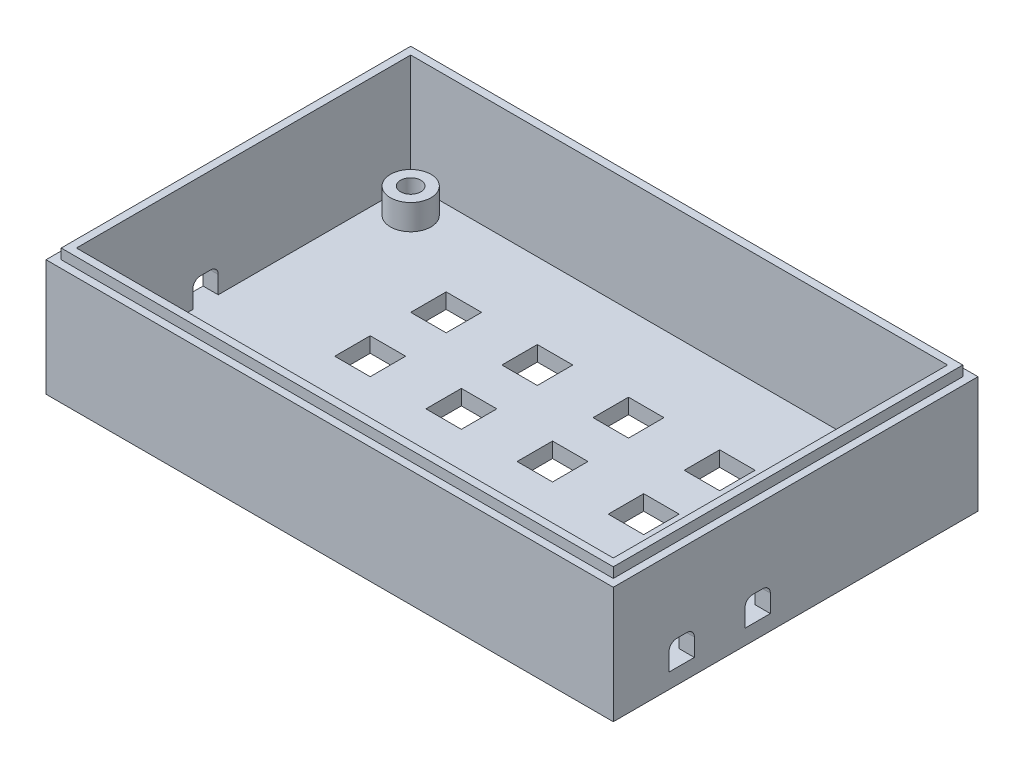
from build123d import *

# Parameters (mm, degrees)
SKETCH1_W                = 106
SKETCH1_H                = 66
SKETCH1_R                = 2
BOSS_EXTRUDE1_DEPTH      = 3
SKETCH2_W                = 112
SKETCH2_H                = 72
SKETCH2_W_2              = 106
SKETCH2_H_2              = 66
BOSS_EXTRUDE2_DEPTH      = 20
BOSS_EXTRUDE2_DEPTH_BACK = 3
SKETCH4_W                = 109
SKETCH4_H                = 69
SKETCH4_W_2              = 106
SKETCH4_H_2              = 66
BOSS_EXTRUDE3_DEPTH      = 2
CUT_EXTRUDE1_DEPTH       = 4
SKETCH6_R                = 4
SKETCH6_R_2              = 2
BOSS_EXTRUDE4_DEPTH      = 5
SKETCH7_W                = 7
SKETCH7_H                = 7
CUT_EXTRUDE2_DEPTH       = 4


with BuildPart() as part:
    # Sketch1 → Boss-Extrude1 (new body)
    with BuildSketch(Plane(origin=(0, 0, 0), x_dir=(1, 0, 0), z_dir=(0, 1, 0))):
        Rectangle(SKETCH1_W, SKETCH1_H)
        with Locations((-47.6, 27.6)):
            Circle(SKETCH1_R, mode=Mode.SUBTRACT)
        with Locations((47.6, 27.6)):
            Circle(SKETCH1_R, mode=Mode.SUBTRACT)
        with Locations((47.6, -27.6)):
            Circle(SKETCH1_R, mode=Mode.SUBTRACT)
        with Locations((-47.6, -27.6)):
            Circle(SKETCH1_R, mode=Mode.SUBTRACT)
    extrude(amount=BOSS_EXTRUDE1_DEPTH)

    # Sketch2 → Boss-Extrude2 (add, two sides)
    with BuildSketch(Plane(origin=(0, 3, 0), x_dir=(1, 0, 0), z_dir=(0, 1, 0))) as boss_extrude2_sk:
        Rectangle(SKETCH2_W, SKETCH2_H)
        Rectangle(SKETCH2_W_2, SKETCH2_H_2, mode=Mode.SUBTRACT)
    extrude(amount=BOSS_EXTRUDE2_DEPTH)
    extrude(boss_extrude2_sk.sketch, amount=-BOSS_EXTRUDE2_DEPTH_BACK)

    # Sketch4 → Boss-Extrude3 (add)
    with BuildSketch(Plane(origin=(0, 23, 0), x_dir=(1, 0, 0), z_dir=(0, 1, 0))):
        Rectangle(SKETCH4_W, SKETCH4_H)
        Rectangle(SKETCH4_W_2, SKETCH4_H_2, mode=Mode.SUBTRACT)
    extrude(amount=BOSS_EXTRUDE3_DEPTH)

    # Sketch5 → Cut-Extrude1 (cut, through all)
    with BuildSketch(Plane.ZY.offset(-53)):
        with BuildLine():
            Line((5, 3), (10, 3))
            Line((10, 3), (10, 6.5))
            ThreePointArc((10, 6.5), (9.560660172, 7.560660172), (8.5, 8))
            Line((8.5, 8), (6.5, 8))
            ThreePointArc((6.5, 8), (5.439339828, 7.560660172), (5, 6.5))
            Line((5, 6.5), (5, 3))
        make_face()
        with BuildLine():
            Line((20, 3), (25, 3))
            Line((25, 3), (25, 6.5))
            ThreePointArc((25, 6.5), (24.560660172, 7.560660172), (23.5, 8))
            Line((23.5, 8), (21.5, 8))
            ThreePointArc((21.5, 8), (20.439339828, 7.560660172), (20, 6.5))
            Line((20, 6.5), (20, 3))
        make_face()
    cut_extrude1 = extrude(amount=-CUT_EXTRUDE1_DEPTH, mode=Mode.SUBTRACT)

    # Sketch6 → Boss-Extrude4 (add)
    with BuildSketch(Plane(origin=(0, 3, 0), x_dir=(1, 0, 0), z_dir=(0, 1, 0))):
        with Locations((-47.6, 27.6)):
            Circle(SKETCH6_R)
        with Locations((-47.6, 27.6)):
            Circle(SKETCH6_R_2, mode=Mode.SUBTRACT)
        with Locations((47.6, 27.6)):
            Circle(SKETCH6_R)
        with Locations((47.6, 27.6)):
            Circle(SKETCH6_R_2, mode=Mode.SUBTRACT)
        with Locations((47.6, -27.6)):
            Circle(SKETCH6_R)
        with Locations((47.6, -27.6)):
            Circle(SKETCH6_R_2, mode=Mode.SUBTRACT)
        with Locations((-47.6, -27.6)):
            Circle(SKETCH6_R)
        with Locations((-47.6, -27.6)):
            Circle(SKETCH6_R_2, mode=Mode.SUBTRACT)
    extrude(amount=BOSS_EXTRUDE4_DEPTH)

    # Sketch7 → Cut-Extrude2 (cut, through all)
    with BuildSketch(Plane(origin=(0, 3, 0), x_dir=(1, 0, 0), z_dir=(0, 1, 0))):
        with Locations((-9.5, 14.5)):
            Rectangle(SKETCH7_W, SKETCH7_H)
        with Locations((-27.5, 14.5)):
            Rectangle(SKETCH7_W, SKETCH7_H)
        with Locations((8.5, 14.5)):
            Rectangle(SKETCH7_W, SKETCH7_H)
        with Locations((26.5, 14.5)):
            Rectangle(SKETCH7_W, SKETCH7_H)
        with Locations((-9.5, -0.5)):
            Rectangle(SKETCH7_W, SKETCH7_H)
        with Locations((8.5, -0.5)):
            Rectangle(SKETCH7_W, SKETCH7_H)
        with Locations((26.5, -0.5)):
            Rectangle(SKETCH7_W, SKETCH7_H)
        with Locations((-9.5, -15.5)):
            Rectangle(SKETCH7_W, SKETCH7_H)
        with Locations((8.5, -15.5)):
            Rectangle(SKETCH7_W, SKETCH7_H)
        with Locations((26.5, -15.5)):
            Rectangle(SKETCH7_W, SKETCH7_H)
        with Locations((-27.5, -0.5)):
            Rectangle(SKETCH7_W, SKETCH7_H)
        with Locations((-27.5, -15.5)):
            Rectangle(SKETCH7_W, SKETCH7_H)
    extrude(amount=-CUT_EXTRUDE2_DEPTH, mode=Mode.SUBTRACT)

    # Mirror1: Cut-Extrude1 across plane
    add(cut_extrude1.mirror(Plane(origin=(0, 0, 0), x_dir=(0, 0, 1), z_dir=(1, 0, 0))), mode=Mode.SUBTRACT)


solid = part.part
